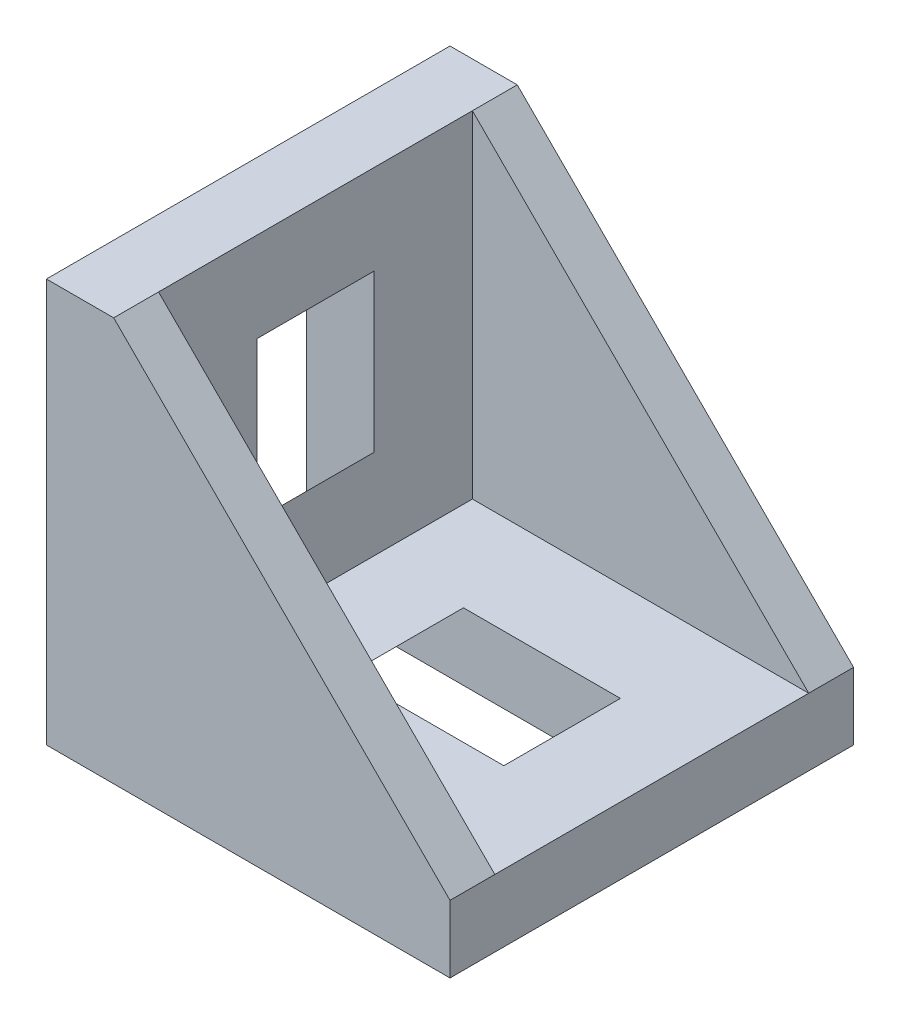
from build123d import *

# Parameters (mm, degrees)
BOSS_EXTRUDE1_DEPTH = 9
CUT_EXTRUDE1_DEPTH  = 7
CUT_EXTRUDE2_DEPTH  = 2.6
BOSS_EXTRUDE2_DEPTH = 3


with BuildPart() as part:
    # Sketch1 → Boss-Extrude1 (new body, symmetric)
    with BuildSketch(Plane.XY):
        Polygon((0, 0), (0, 18), (3, 18), (18, 3), (18, 0), align=None)
    extrude(amount=BOSS_EXTRUDE1_DEPTH, both=True)

    # Sketch2 → Cut-Extrude1 (cut, symmetric)
    with BuildSketch(Plane.XY):
        Polygon((3, 18), (3, 3), (18, 3), align=None)
    extrude(amount=CUT_EXTRUDE1_DEPTH, both=True, mode=Mode.SUBTRACT)

    # Sketch3 → Cut-Extrude2 (cut, symmetric)
    with BuildSketch(Plane.XY):
        Polygon((0, 14), (3, 14), (3, 7), (0, 4), align=None)
        Polygon((7, 3), (14, 3), (14, 0), (4, 0), align=None)
    extrude(amount=CUT_EXTRUDE2_DEPTH, both=True, mode=Mode.SUBTRACT)

    # Sketch4 → Boss-Extrude2 (add, symmetric)
    with BuildSketch(Plane.XY):
        Polygon((1.497483368, -1.80628538), (0.504853677, -0.797938337), (1.234750477, 0), (3.535533906, 0), align=None)
        Polygon((0, 3.535533906), (-1.80628538, 1.497483368), (-0.797938337, 0.504853677), (0, 1.234750477), align=None)
        Polygon((0, 17.3), (0, 14.999216572), (-0.797938337, 14.269319771), (-1.80628538, 15.261949462), align=None)
        Polygon((14.999216572, 0), (14.269319771, -0.797938337), (15.261949462, -1.80628538), (17.3, 0), align=None)
    extrude(amount=BOSS_EXTRUDE2_DEPTH, both=True)


solid = part.part
